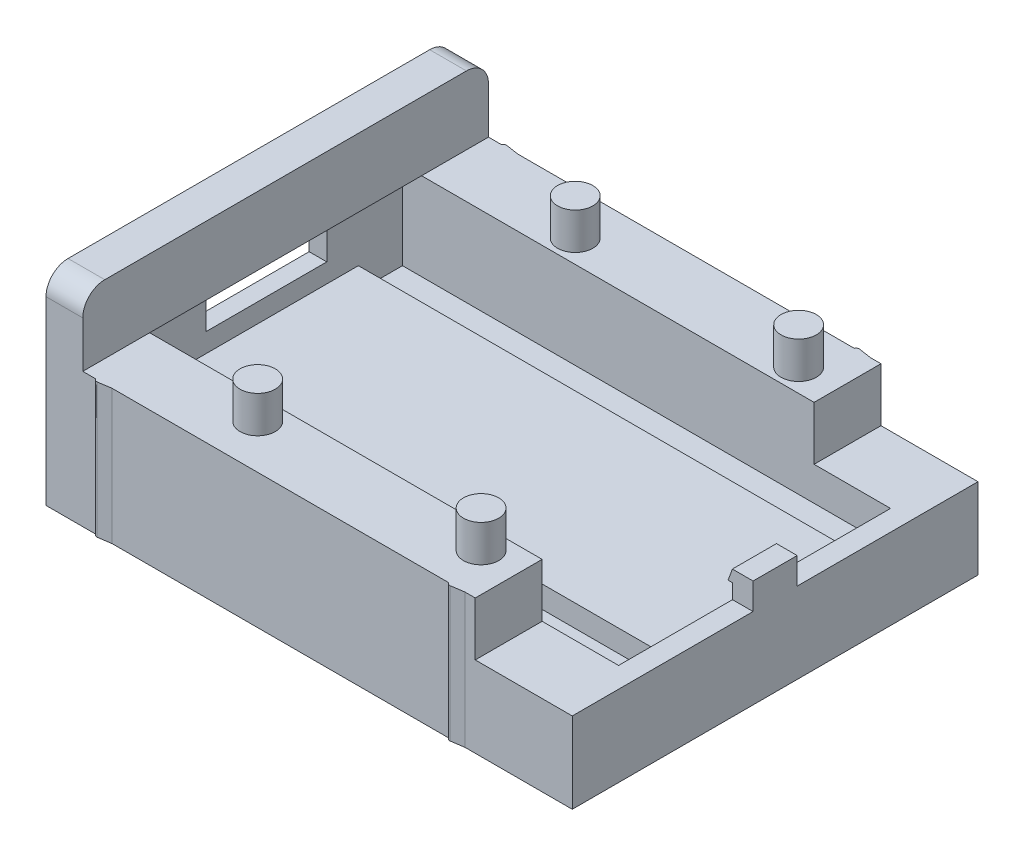
from build123d import *

# Parameters (mm, degrees)
SKIZZE2_W                       = 28
SKIZZE2_H                       = 4
AUFSATZ_LINEAR_AUSTRAGEN2_DEPTH = 17.9
SKIZZE4_W                       = 35.8
SKIZZE4_H                       = 28
AUFSATZ_LINEAR_AUSTRAGEN3_DEPTH = 5
SKIZZE7_W                       = 8.2
SKIZZE7_H                       = 3
SCHNITT_LINEAR_AUSTRAGEN4_DEPTH = 1.5
SKIZZE5_W                       = 33.2
SKIZZE5_H                       = 18.5
SCHNITT_LINEAR_AUSTRAGEN2_DEPTH = 4.3
SKIZZE8_W                       = 34.6
SKIZZE8_H                       = 28
SCHNITT_LINEAR_AUSTRAGEN5_DEPTH = 3.5
AUFSATZ_LINEAR_AUSTRAGEN4_DEPTH = 1.5
SKIZZE9_W                       = 33.2
SKIZZE9_H                       = 3
SCHNITT_LINEAR_AUSTRAGEN6_DEPTH = 1.5
SKIZZE11_W                      = 28
SKIZZE11_H                      = 4.8
AUFSATZ_LINEAR_AUSTRAGEN5_DEPTH = 1.2
SKIZZE12_W                      = 28
SKIZZE12_H                      = 4.75
AUFSATZ_LINEAR_AUSTRAGEN6_DEPTH = 3.65
SKIZZE13_R                      = 1.2
AUFSATZ_LINEAR_AUSTRAGEN7_DEPTH = 2.5
LINEARES_MUSTER1_COUNT          = 2
LINEARES_MUSTER1_PITCH          = 15.2
LINEARES_MUSTER1_COUNT_DIR2     = 2
LINEARES_MUSTER1_PITCH_DIR2     = 21.6
SCHNITT_LINEAR_AUSTRAGEN7_DEPTH = 14.8
VERRUNDUNG1_R                   = 0.2
SKIZZE20_W                      = 27.6
SKIZZE20_H                      = 4.65
AUFSATZ_LINEAR_AUSTRAGEN8_DEPTH = 1.3
VERRUNDUNG2_R                   = 1.5
SCHNITT_LINEAR_AUSTRAGEN8_DEPTH = 1


with BuildPart() as part:
    # Skizze2 → Aufsatz-Linear austragen2 (new body, symmetric)
    with BuildSketch(Plane(origin=(0, 0, 0), x_dir=(0, 0, -1), z_dir=(1, 0, 0))):
        with Locations((0, -2)):
            Rectangle(SKIZZE2_W, SKIZZE2_H)
    extrude(amount=AUFSATZ_LINEAR_AUSTRAGEN2_DEPTH, both=True)

    # Skizze4 → Aufsatz-Linear austragen3 (add)
    with BuildSketch(Plane(origin=(0, 0, 0), x_dir=(1, 0, 0), z_dir=(0, 1, 0))):
        Rectangle(SKIZZE4_W, SKIZZE4_H)
    extrude(amount=AUFSATZ_LINEAR_AUSTRAGEN3_DEPTH)

    # Skizze7 → Schnitt-Linear austragen4 (cut)
    with BuildSketch(Plane.ZY.offset(17.9)):
        with Locations((0, 3.5)):
            Rectangle(SKIZZE7_W, SKIZZE7_H)
    extrude(amount=-SCHNITT_LINEAR_AUSTRAGEN4_DEPTH, mode=Mode.SUBTRACT)

    # Skizze5 → Schnitt-Linear austragen2 (cut)
    with BuildSketch(Plane(origin=(0, 5, 0), x_dir=(1, 0, 0), z_dir=(0, 1, 0))):
        with Locations((-0.1, 0)):
            Rectangle(SKIZZE5_W, SKIZZE5_H)
    extrude(amount=-SCHNITT_LINEAR_AUSTRAGEN2_DEPTH, mode=Mode.SUBTRACT)

    # Skizze8 → Schnitt-Linear austragen5 (cut)
    with BuildSketch(Plane(origin=(0, 5, 0), x_dir=(1, 0, 0), z_dir=(0, 1, 0))):
        with Locations((0.6, 0)):
            Rectangle(SKIZZE8_W, SKIZZE8_H)
    extrude(amount=-SCHNITT_LINEAR_AUSTRAGEN5_DEPTH, mode=Mode.SUBTRACT)

    # Skizze10 → Aufsatz-Linear austragen4 (add, symmetric)
    with BuildSketch(Plane.XY):
        Polygon((17.9, 1.5), (16.5, 1.5), (16.5, 2.5), (16.2, 2.5), (16.491176187, 3.3), (17.9, 3.3), align=None)
    extrude(amount=AUFSATZ_LINEAR_AUSTRAGEN4_DEPTH, both=True)

    # Skizze9 → Schnitt-Linear austragen6 (cut)
    with BuildSketch(Plane(origin=(0, 0.7, 0), x_dir=(1, 0, 0), z_dir=(0, 1, 0))):
        with Locations((-0.1, -7.75)):
            Rectangle(SKIZZE9_W, SKIZZE9_H)
        with Locations((-0.1, 7.75)):
            Rectangle(SKIZZE9_W, SKIZZE9_H)
    extrude(amount=-SCHNITT_LINEAR_AUSTRAGEN6_DEPTH, mode=Mode.SUBTRACT)

    # Skizze11 → Aufsatz-Linear austragen5 (add)
    with BuildSketch(Plane.ZY.offset(17.9)):
        with Locations((0, 7.4)):
            Rectangle(SKIZZE11_W, SKIZZE11_H)
    extrude(amount=-AUFSATZ_LINEAR_AUSTRAGEN5_DEPTH)

    # Skizze12 → Aufsatz-Linear austragen6 (add)
    with BuildSketch(Plane(origin=(0, 1.5, 0), x_dir=(1, 0, 0), z_dir=(0, 1, 0))):
        with Locations((-2.7, 11.625)):
            Rectangle(SKIZZE12_W, SKIZZE12_H)
        with Locations((-2.7, -11.625)):
            Rectangle(SKIZZE12_W, SKIZZE12_H)
    extrude(amount=AUFSATZ_LINEAR_AUSTRAGEN6_DEPTH)

    # Skizze13 → Aufsatz-Linear austragen7 (add)
    with BuildSketch(Plane(origin=(0, 5.15, 0), x_dir=(1, 0, 0), z_dir=(0, 1, 0))):
        with Locations((-6.5, 10.8)):
            Circle(SKIZZE13_R)
    aufsatz_linear_austragen7 = extrude(amount=AUFSATZ_LINEAR_AUSTRAGEN7_DEPTH)

    # Lineares Muster1: Aufsatz-Linear austragen7 2 × 2
    with Locations(*[(i * LINEARES_MUSTER1_PITCH, 0, j * LINEARES_MUSTER1_PITCH_DIR2) for i in range(LINEARES_MUSTER1_COUNT) for j in range(LINEARES_MUSTER1_COUNT_DIR2) if (i, j) != (0, 0)]):
        add(aufsatz_linear_austragen7)

    # Skizze14 → Schnitt-Linear austragen7 (cut, through all)
    with BuildSketch(Plane.XZ.offset(4)):
        Polygon((-17.9, -14), (-17.9, -13.8), (-14.51944695, -13.8), (-14.4, -13.95), (-13.4, -13.8), (9.48055305, -13.8), (9.6, -13.95), (10.6, -13.8), (17.9, -13.8), (17.9, -14), align=None)
        Polygon((10.6, 13.8), (17.9, 13.8), (17.9, 14), (-17.9, 14), (-17.9, 13.8), (-14.51944695, 13.8), (-14.4, 13.95), (-13.4, 13.8), (9.48055305, 13.8), (9.6, 13.95), align=None)
    extrude(amount=-SCHNITT_LINEAR_AUSTRAGEN7_DEPTH, mode=Mode.SUBTRACT)

    # Verrundung1
    verrundung1_edges = [part.edges().sort_by_distance(p)[0] for p in [
        (-14.4, 0.575, -13.95),
        (9.6, 0.575, -13.95),
        (9.6, 0.575, 13.95),
        (-14.4, 0.575, 13.95),
    ]]
    fillet(verrundung1_edges, radius=VERRUNDUNG1_R)

    # Skizze20 → Aufsatz-Linear austragen8 (add)
    with BuildSketch(Plane(origin=(-16.7, 0, 0), x_dir=(0, 0, -1), z_dir=(1, 0, 0))):
        with Locations((0, 7.475)):
            Rectangle(SKIZZE20_W, SKIZZE20_H)
    extrude(amount=AUFSATZ_LINEAR_AUSTRAGEN8_DEPTH)

    # Verrundung2
    verrundung2_edges = [part.edges().sort_by_distance(p)[0] for p in [
        (-16.65, 9.8, -13.8),
        (-16.65, 9.8, 13.8),
    ]]
    fillet(verrundung2_edges, radius=VERRUNDUNG2_R)

    # Skizze21 → Schnitt-Linear austragen8 (cut)
    with BuildSketch(Plane.ZY.offset(17.9)):
        Polygon((-13.218058581, -3.5), (-13.218058581, 0.095646159), (-12.710980277, 0.095646159), (-12.710980277, -3.085117751), (-11.005353253, -3.085117751), (-11.005353253, -3.5), align=None)
    extrude(amount=-SCHNITT_LINEAR_AUSTRAGEN8_DEPTH, mode=Mode.SUBTRACT)


solid = part.part
